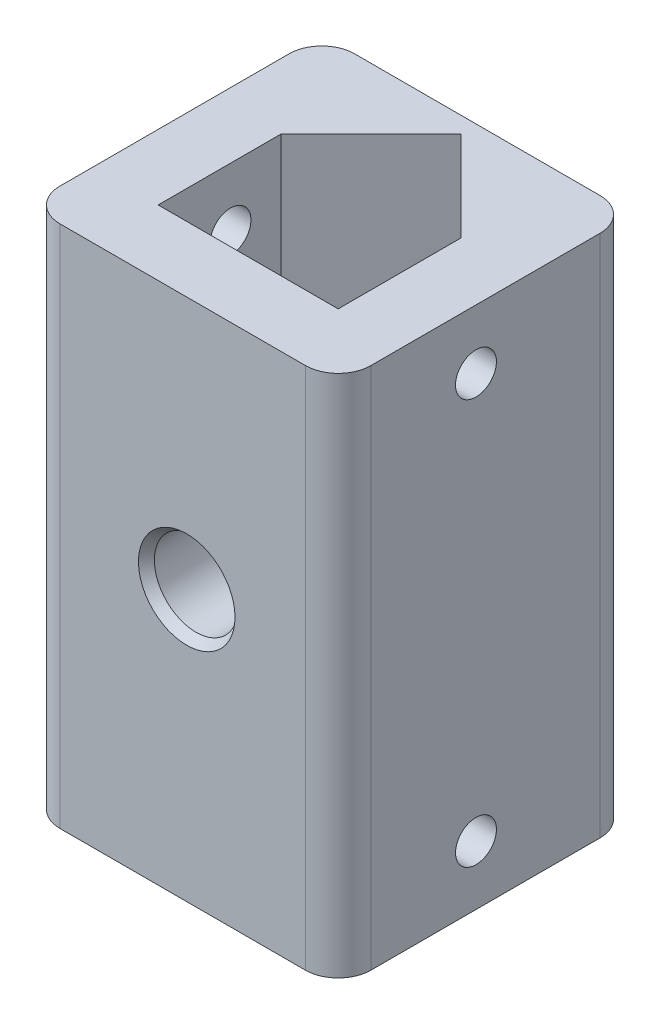
from build123d import *

# Parameters (mm, degrees)
SKETCH1_W                   = 19
SKETCH1_H                   = 18
BOSS_EXTRUDE1_DEPTH         = 32
TAP_DRILL_FOR_M3X0_5_TAP1_D = 2.5
FILLET1_R                   = 2


with BuildPart() as part:
    # Sketch1 → Boss-Extrude1 (new body)
    with BuildSketch(Plane(origin=(0, 0, 0), x_dir=(1, 0, 0), z_dir=(0, 1, 0))):
        with Locations((9.5, 9)):
            Rectangle(SKETCH1_W, SKETCH1_H)
        Polygon((4, 4), (15, 4), (15, 11.5), (9.5, 17), (4, 11.5), align=None, mode=Mode.SUBTRACT)
    extrude(amount=BOSS_EXTRUDE1_DEPTH)

    # Tap Drill for M3x0.5 Tap1 (through all)
    with Locations(Plane(origin=(19, 0, 0), x_dir=(0, 0, -1), z_dir=(1, 0, 0))):
        with Locations((8.419226219, 28.375), (8.419226219, 3.625)):
            Hole(TAP_DRILL_FOR_M3X0_5_TAP1_D / 2)

    # Fillet1
    fillet1_edges = [part.edges().sort_by_distance(p)[0] for p in [
        (0, 16, -18),
        (19, 16, -18),
        (19, 16, 0),
        (0, 16, 0),
    ]]
    fillet(fillet1_edges, radius=FILLET1_R)

    # Sketch5 → M5 Clearance Hole1 (revolve, cut)
    with BuildSketch(Plane(origin=(9.744397645, 16.5210513, 0), x_dir=(0, -1, 0), z_dir=(1, 0, 0))):
        Polygon((0, 0), (0, 4), (2.55, 4), (2.55, 0.571259203), (2.95, 0), align=None)
    revolve(axis=Axis((9.744397645, 16.5210513, 6.35), (0, 0, -1)), mode=Mode.SUBTRACT)


solid = part.part
